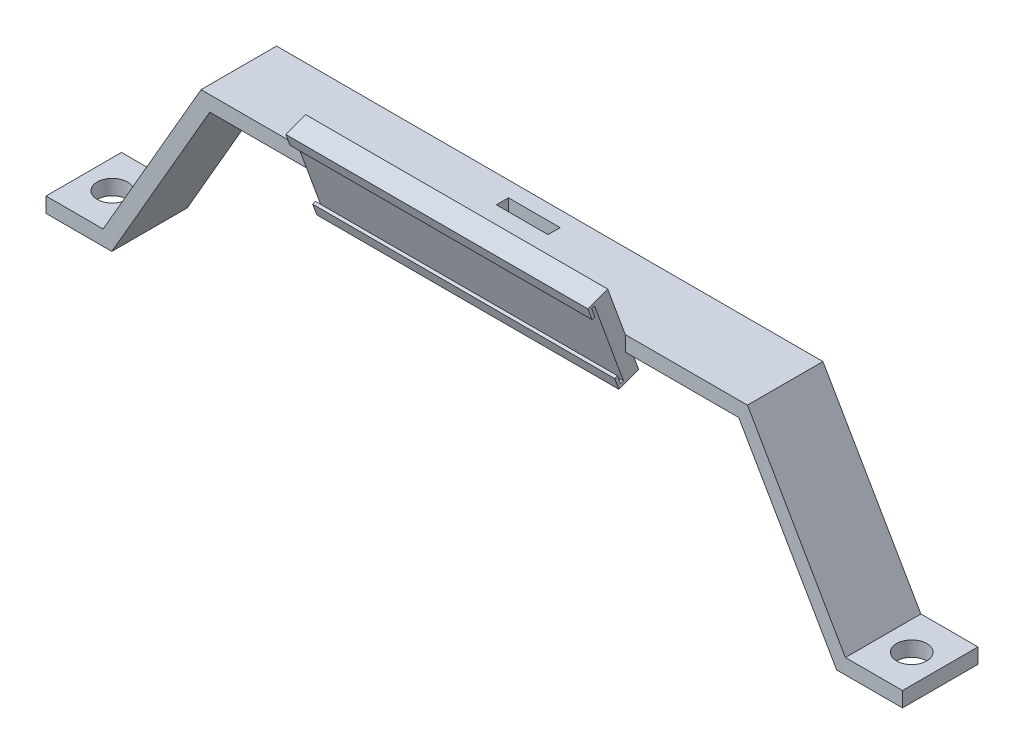
from build123d import *

# Parameters (mm, degrees)
BOSS_EXTRUDE1_DEPTH = 25
SKETCH2_R           = 5
SKETCH2_W           = 17.097123546
SKETCH2_H           = 4.020670456
CUT_EXTRUDE1_DEPTH  = 100
BOSS_EXTRUDE2_DEPTH = 50


with BuildPart() as part:
    # Sketch1 → Boss-Extrude1 (new body)
    with BuildSketch(Plane.XY):
        Polygon((-120, 0), (-87.572195572, 56.166604847), (87.572195572, 56.166604847), (120, 0), (126.793465802, 0), (141.793465802, 0), (141.793465802, 5), (122.886751346, 5), (92.427804428, 57.756443607), (90.458946918, 61.166604847), (-90.458946918, 61.166604847), (-122.886751346, 5), (-141.793465802, 5), (-141.793465802, 0), (-126.793465802, 0), align=None)
    extrude(amount=BOSS_EXTRUDE1_DEPTH)

    # Sketch2 → Cut-Extrude1 (cut, symmetric)
    with BuildSketch(Plane(origin=(0, 5, 0), x_dir=(1, 0, 0), z_dir=(0, 1, 0))):
        with Locations((132.340108574, -12.5)):
            Circle(SKETCH2_R)
        with Locations((-132.340108574, -12.5)):
            Circle(SKETCH2_R)
        with Locations((0, -7.118249896)):
            Rectangle(SKETCH2_W, SKETCH2_H)
    extrude(amount=CUT_EXTRUDE1_DEPTH, both=True, mode=Mode.SUBTRACT)

    # Sketch3 → Boss-Extrude2 (add, symmetric)
    with BuildSketch(Plane(origin=(0, 0, 0), x_dir=(0, 0, -1), z_dir=(1, 0, 0))):
        Polygon((-30.808478502, 77.125268372), (-20.547874202, 48.934489749), (-25.246337306, 47.224389032), (-27.125722548, 46.540348745), (-28.493803121, 50.299119228), (-27.5541105, 50.641139372), (-26.52805007, 47.822061509), (-25.588357449, 48.164081653), (-35.164921463, 74.475475035), (-36.104614083, 74.133454891), (-35.078553653, 71.314377029), (-36.018246274, 70.972356886), (-37.386326847, 74.731127369), (-35.506941606, 75.415167656), align=None)
    extrude(amount=BOSS_EXTRUDE2_DEPTH, both=True)


solid = part.part
